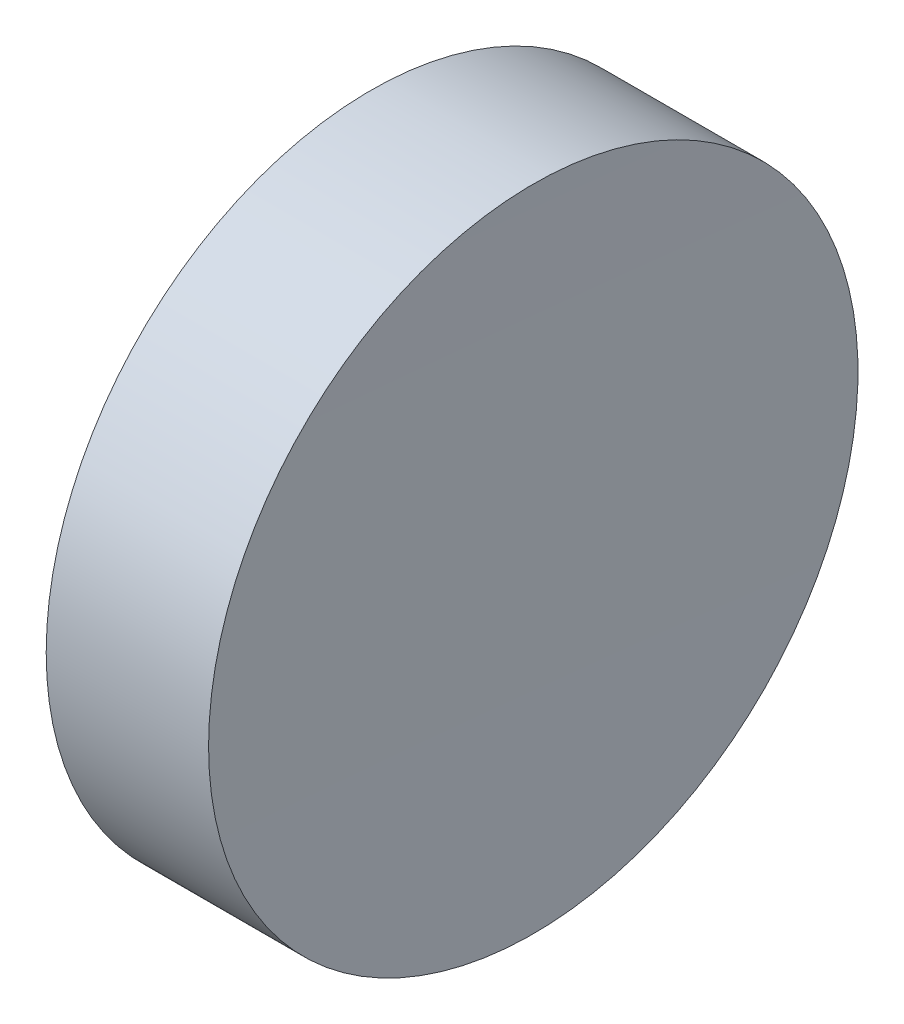
from build123d import *


with BuildPart() as part:
    # 草图1 → 旋转1 (revolve)
    with BuildSketch(Plane(origin=(0, 0, 0), x_dir=(1, 0, 0), z_dir=(0, 1, 0)), mode=Mode.PRIVATE) as revolve_1_sk:
        with BuildLine():
            Line((0, 0), (6.27, 0))
            ThreePointArc((6.27, 0), (6.290162266, 6.350128033), (6.350648252, 12.7))
            Line((6.350648252, 12.7), (0, 12.7))
            Line((0, 12.7), (0, 0))
        make_face()
    revolve(revolve_1_sk.sketch.rotate(Axis((0, 0, 0), (1, 0, 0)), 180), axis=Axis((0, 0, 0), (1, 0, 0)))  # turned: the seam where the file's is


solid = part.part
